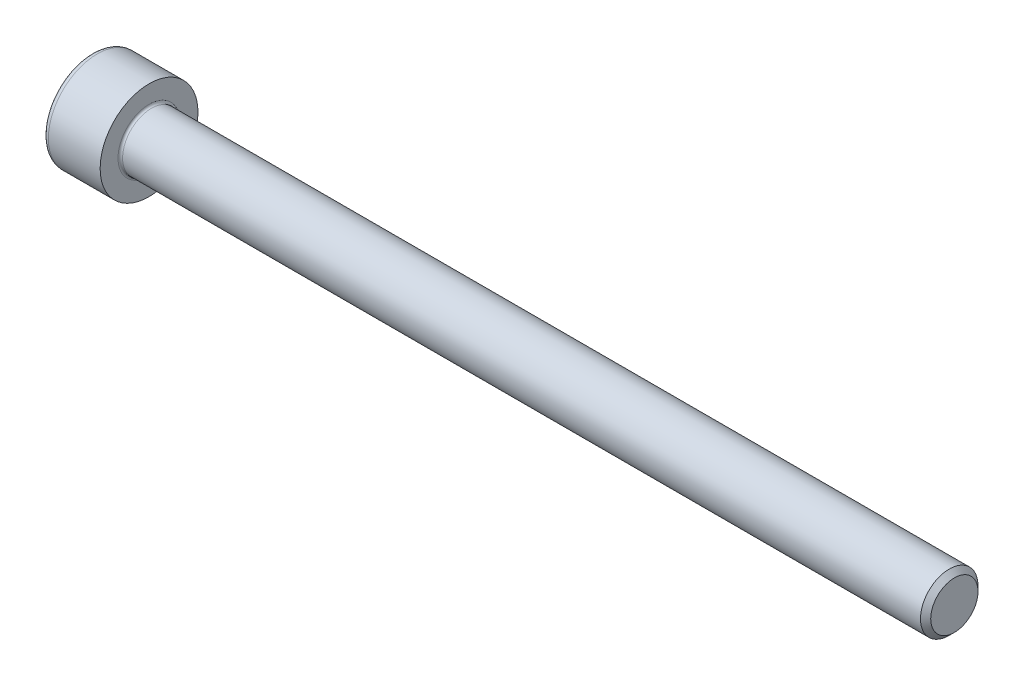
from build123d import *

# Parameters (mm, degrees)
FILLET1_R   = 0.2
FILLET2_R   = 0.5
HEX_2_DEPTH = 2.5


with BuildPart() as part:
    # BodySke → Base-Revolve (revolve)
    with BuildSketch(Plane.XY):
        Polygon((0, 0), (0, 4.25), (5, 4.25), (5, 2.5), (74.555, 2.5), (75, 2.055), (75, 0), align=None)
    revolve(axis=Axis((-31.75, 0, 0), (1, 0, 0)))

    # Fillet1
    fillet1_edges = [part.edges().sort_by_distance(p)[0] for p in [
        (5, -2.5, 0),
    ]]
    fillet(fillet1_edges, radius=FILLET1_R)

    # Fillet2
    fillet2_edges = [part.edges().sort_by_distance(p)[0] for p in [
        (0, -4.25, 0),
    ]]
    fillet(fillet2_edges, radius=FILLET2_R)

    # Sketch2 → Hex-PreBroach (revolve, cut)
    with BuildSketch(Plane.XY):
        Polygon((0, 2.01), (2.5, 2.01), (3.660474041, 0), (0, 0), align=None)
    revolve(axis=Axis((0, 0, 0), (1, 0, 0)), mode=Mode.SUBTRACT)

    # Sketch3 → Hex 2 (cut)
    with BuildSketch(Plane(origin=(0, 0, 0), x_dir=(0, 0.5, 0.866025404), z_dir=(-1, 0, 0))):
        Polygon((1.160474041, 2.01), (-1.160474041, 2.01), (-2.320948082, 0), (-1.160474041, -2.01), (1.160474041, -2.01), (2.320948082, 0), align=None)
    extrude(amount=-HEX_2_DEPTH, mode=Mode.SUBTRACT)


solid = part.part
